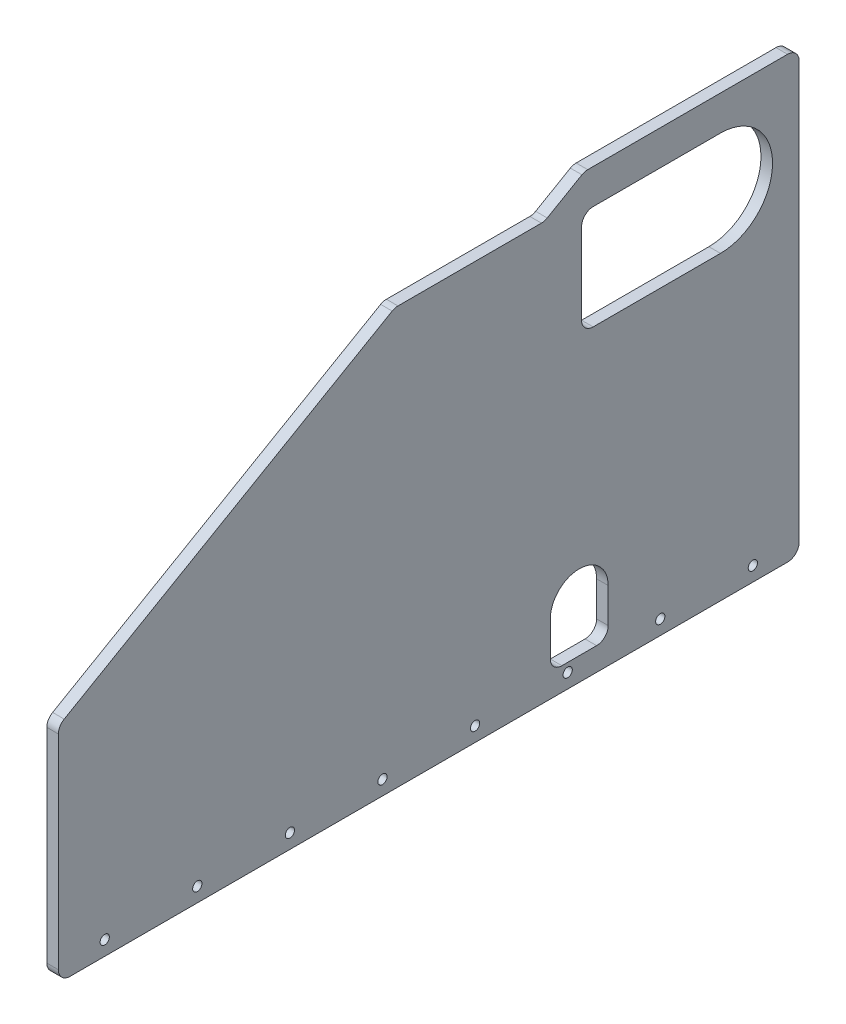
from build123d import *

# Parameters (mm, degrees)
BOSS_EXTRUDE1_DEPTH = 6.35
SKETCH3_R           = 3.96875
CUT_EXTRUDE1_DEPTH  = 7.35
SKETCH5_W           = 6.35
SKETCH5_H           = 12.7
CUT_EXTRUDE3_DEPTH  = 7.35
LPATTERN1_COUNT     = 16
LPATTERN1_PITCH     = 25.4
SKETCH6_W           = 6.35
SKETCH6_H           = 12.7
CUT_EXTRUDE4_DEPTH  = 7.35
LPATTERN2_COUNT     = 11
LPATTERN2_PITCH     = 25.4
SKETCH7_W           = 6.35
SKETCH7_H           = 12.7
SKETCH7_W_2         = 12.7
SKETCH7_H_2         = 6.35
CUT_EXTRUDE5_DEPTH  = 7.35
CUT_EXTRUDE6_DEPTH  = 7.35
LPATTERN3_COUNT     = 10
LPATTERN3_PITCH     = 25.4
SKETCH9_W           = 12.7
SKETCH9_H           = 6.35
CUT_EXTRUDE7_DEPTH  = 7.35
LPATTERN4_COUNT     = 8
LPATTERN4_PITCH     = 25.4
SKETCH10_R          = 3.175
CUT_EXTRUDE8_DEPTH  = 7.35
SKETCH11_R          = 3.96875
CUT_EXTRUDE9_DEPTH  = 7.35
SKETCH12_W          = 6.35
SKETCH12_H          = 12.7
CUT_EXTRUDE13_DEPTH = 7.35
CUT_EXTRUDE15_DEPTH = 7.35
CUT_EXTRUDE16_DEPTH = 7.35
SKETCH17_W          = 12.7
SKETCH17_H          = 6.35
CUT_EXTRUDE17_DEPTH = 7.35
LPATTERN5_COUNT     = 17
LPATTERN5_PITCH     = 25.4
LPATTERN6_COUNT     = 2
LPATTERN6_PITCH     = 120.65
SKETCH18_W          = 12.7
SKETCH18_H          = 6.35
CUT_EXTRUDE18_DEPTH = 7.35
LPATTERN7_COUNT     = 5
LPATTERN7_PITCH     = 25.4
CUT_EXTRUDE19_DEPTH = 7.35
SKETCH20_W          = 101.6
SKETCH20_H          = 57.15
CUT_EXTRUDE20_DEPTH = 7.35
CUT_EXTRUDE21_DEPTH = 7.35
CUT_EXTRUDE22_DEPTH = 7.35
BOSS_EXTRUDE4_DEPTH = 6.35
BOSS_EXTRUDE5_DEPTH = 6.35
CUT_EXTRUDE23_DEPTH = 7.35
CUT_EXTRUDE24_DEPTH = 7.35
FILLET1_R           = 6.35
SKETCH30_R          = 2.54
CUT_EXTRUDE25_DEPTH = 7.35
SKETCH31_W          = 76.2
SKETCH31_H          = 57.15
CUT_EXTRUDE26_DEPTH = 7.35
CUT_EXTRUDE27_DEPTH = 7.35
SKETCH33_W          = 110.352574347
SKETCH33_H          = 42.11476807
CUT_EXTRUDE28_DEPTH = 7.35
FILLET2_R           = 6.35


with BuildPart() as part:
    # Sketch2 → Boss-Extrude1 (new body)
    with BuildSketch(Plane(origin=(0, 0, 0), x_dir=(0, 0, -1), z_dir=(1, 0, 0))):
        Polygon((0, 0), (0, 294.450076882), (215.9, 419.1), (431.8, 419.1), (431.8, 0), (241.3, 0), (241.3, 38.1), (127, 38.1), (127, 0), align=None)
    extrude(amount=BOSS_EXTRUDE1_DEPTH)

    # Sketch3 → Cut-Extrude1 (cut, through all)
    with BuildSketch(Plane(origin=(6.35, 0, 0), x_dir=(0, 0, -1), z_dir=(1, 0, 0))):
        with Locations((63.5, 38.1)):
            Circle(SKETCH3_R)
        with Locations((368.3, 38.1)):
            Circle(SKETCH3_R)
    extrude(amount=-CUT_EXTRUDE1_DEPTH, mode=Mode.SUBTRACT)

    # Sketch5 → Cut-Extrude3 (cut, through all)
    with BuildSketch(Plane(origin=(6.35, 0, 0), x_dir=(0, 0, -1), z_dir=(1, 0, 0))):
        with Locations((428.625, 19.05)):
            Rectangle(SKETCH5_W, SKETCH5_H)
    cut_extrude3 = extrude(amount=-CUT_EXTRUDE3_DEPTH, mode=Mode.SUBTRACT)

    # LPattern1: Cut-Extrude3 ×16
    with Locations(*[(0, i * LPATTERN1_PITCH, 0) for i in range(1, LPATTERN1_COUNT)]):
        add(cut_extrude3, mode=Mode.SUBTRACT)

    # Sketch6 → Cut-Extrude4 (cut, through all)
    with BuildSketch(Plane(origin=(6.35, 0, 0), x_dir=(0, 0, -1), z_dir=(1, 0, 0))):
        with Locations((3.175, 19.05)):
            Rectangle(SKETCH6_W, SKETCH6_H)
    cut_extrude4 = extrude(amount=-CUT_EXTRUDE4_DEPTH, mode=Mode.SUBTRACT)

    # LPattern2: Cut-Extrude4 ×11
    with Locations(*[(0, i * LPATTERN2_PITCH, 0) for i in range(1, LPATTERN2_COUNT)]):
        add(cut_extrude4, mode=Mode.SUBTRACT)

    # Sketch7 → Cut-Extrude5 (cut, through all)
    with BuildSketch(Plane(origin=(6.35, 0, 0), x_dir=(0, 0, -1), z_dir=(1, 0, 0))):
        with Locations((123.825, 19.05)):
            Rectangle(SKETCH7_W, SKETCH7_H)
        with Locations((133.35, 41.275)):
            Rectangle(SKETCH7_W_2, SKETCH7_H_2)
        with Locations((158.75, 41.275)):
            Rectangle(SKETCH7_W_2, SKETCH7_H_2)
        with Locations((184.15, 41.275)):
            Rectangle(SKETCH7_W_2, SKETCH7_H_2)
        with Locations((244.475, 19.05)):
            Rectangle(SKETCH7_W, SKETCH7_H)
        with Locations((209.55, 41.275)):
            Rectangle(SKETCH7_W_2, SKETCH7_H_2)
        with Locations((234.95, 41.275)):
            Rectangle(SKETCH7_W_2, SKETCH7_H_2)
    extrude(amount=-CUT_EXTRUDE5_DEPTH, mode=Mode.SUBTRACT)

    # Sketch8 → Cut-Extrude6 (cut, through all)
    with BuildSketch(Plane(origin=(6.35, 0, 0), x_dir=(0, 0, -1), z_dir=(1, 0, 0))):
        Polygon((201.93507044, 411.037344159), (212.933593068, 417.387344159), (216.108593068, 411.888082845), (205.11007044, 405.538082845), align=None)
    cut_extrude6 = extrude(amount=-CUT_EXTRUDE6_DEPTH, mode=Mode.SUBTRACT)

    # LPattern3: Cut-Extrude6 ×10
    with Locations(*[Vector(0, -0.5, 0.866025404) * (i * LPATTERN3_PITCH) for i in range(1, LPATTERN3_COUNT)]):
        add(cut_extrude6, mode=Mode.SUBTRACT)

    # Sketch9 → Cut-Extrude7 (cut, through all)
    with BuildSketch(Plane(origin=(6.35, 0, 0), x_dir=(0, 0, -1), z_dir=(1, 0, 0))):
        with Locations((412.75, 415.925)):
            Rectangle(SKETCH9_W, SKETCH9_H)
    cut_extrude7 = extrude(amount=-CUT_EXTRUDE7_DEPTH, mode=Mode.SUBTRACT)

    # LPattern4: Cut-Extrude7 ×8
    with Locations(*[(0, 0, i * LPATTERN4_PITCH) for i in range(1, LPATTERN4_COUNT)]):
        add(cut_extrude7, mode=Mode.SUBTRACT)

    # Sketch10 → Cut-Extrude8 (cut, through all)
    with BuildSketch(Plane(origin=(6.35, 0, 0), x_dir=(0, 0, -1), z_dir=(1, 0, 0))):
        with Locations((222.25, 273.05)):
            Circle(SKETCH10_R)
        with Locations((222.25, 57.15)):
            Circle(SKETCH10_R)
        with Locations((146.05, 57.15)):
            Circle(SKETCH10_R)
        with Locations((146.05, 273.05)):
            Circle(SKETCH10_R)
    extrude(amount=-CUT_EXTRUDE8_DEPTH, mode=Mode.SUBTRACT)

    # Sketch11 → Cut-Extrude9 (cut, through all)
    with BuildSketch(Plane(origin=(6.35, 0, 0), x_dir=(0, 0, -1), z_dir=(1, 0, 0))):
        with Locations((38.1, 260.35)):
            Circle(SKETCH11_R)
        with Locations((266.7, 260.35)):
            Circle(SKETCH11_R)
    extrude(amount=-CUT_EXTRUDE9_DEPTH, mode=Mode.SUBTRACT)

    # Sketch12 → Cut-Extrude13 (cut, through all)
    with BuildSketch(Plane(origin=(6.35, 0, 0), x_dir=(0, 0, -1), z_dir=(1, 0, 0))):
        with Locations((123.825, 44.45)):
            Rectangle(SKETCH12_W, SKETCH12_H)
        with Locations((123.825, 69.85)):
            Rectangle(SKETCH12_W, SKETCH12_H)
        with Locations((123.825, 95.25)):
            Rectangle(SKETCH12_W, SKETCH12_H)
        with Locations((123.825, 120.65)):
            Rectangle(SKETCH12_W, SKETCH12_H)
    cut_extrude13 = extrude(amount=-CUT_EXTRUDE13_DEPTH, mode=Mode.SUBTRACT)

    # Sketch14 → Cut-Extrude15 (cut, through all)
    with BuildSketch(Plane(origin=(6.35, 0, 0), x_dir=(0, 0, -1), z_dir=(1, 0, 0))):
        Polygon((36.957231019, 315.787344159), (47.955753647, 322.137344159), (51.130753647, 316.638082845), (40.132231019, 310.288082845), align=None)
        Polygon((80.951321531, 341.187344159), (91.949844159, 347.537344159), (95.124844159, 342.038082845), (84.126321531, 335.688082845), align=None)
    extrude(amount=-CUT_EXTRUDE15_DEPTH, mode=Mode.SUBTRACT)

    # Sketch15 → Cut-Extrude16 (cut, through all)
    with BuildSketch(Plane(origin=(6.35, 0, 0), x_dir=(0, 0, -1), z_dir=(1, 0, 0))):
        with BuildLine():
            Line((62.129276275, 322.988082845), (31.558579521, 305.338082845))
            ThreePointArc((31.558579521, 305.338082845), (51.535904978, 302.314952438), (62.501260575, 319.285333297))
            ThreePointArc((62.501260575, 319.285333297), (62.408031035, 321.146027155), (62.129276275, 322.988082845))
        make_face()
        with BuildLine():
            Line((103.698495657, 346.988082845), (73.127798903, 329.338082845))
            ThreePointArc((73.127798903, 329.338082845), (93.10512436, 326.314952438), (104.070479957, 343.285333297))
            ThreePointArc((104.070479957, 343.285333297), (103.977250417, 345.146027155), (103.698495657, 346.988082845))
        make_face()
    extrude(amount=-CUT_EXTRUDE16_DEPTH, mode=Mode.SUBTRACT)

    # Sketch17 → Cut-Extrude17 (cut, through all)
    with BuildSketch(Plane(origin=(6.35, 0, 0), x_dir=(0, 0, -1), z_dir=(1, 0, 0))):
        with Locations((25.4, 142.875)):
            Rectangle(SKETCH17_W, SKETCH17_H)
    cut_extrude17 = extrude(amount=-CUT_EXTRUDE17_DEPTH, mode=Mode.SUBTRACT)

    # LPattern5: Cut-Extrude17 ×17
    with Locations(*[(0, 0, -i * LPATTERN5_PITCH) for i in range(1, LPATTERN5_COUNT)]):
        add(cut_extrude17, mode=Mode.SUBTRACT)

    # LPattern6: Cut-Extrude13 ×2
    with Locations(*[(0, 0, -i * LPATTERN6_PITCH) for i in range(1, LPATTERN6_COUNT)]):
        add(cut_extrude13, mode=Mode.SUBTRACT)

    # Sketch18 → Cut-Extrude18 (cut, through all)
    with BuildSketch(Plane(origin=(6.35, 0, 0), x_dir=(0, 0, -1), z_dir=(1, 0, 0))):
        with Locations((133.35, 117.475)):
            Rectangle(SKETCH18_W, SKETCH18_H)
    cut_extrude18 = extrude(amount=-CUT_EXTRUDE18_DEPTH, mode=Mode.SUBTRACT)

    # LPattern7: Cut-Extrude18 ×5
    with Locations(*[(0, 0, -i * LPATTERN7_PITCH) for i in range(1, LPATTERN7_COUNT)]):
        add(cut_extrude18, mode=Mode.SUBTRACT)

    # Sketch19 → Cut-Extrude19 (cut, through all)
    with BuildSketch(Plane(origin=(6.35, 0, 0), x_dir=(0, 0, -1), z_dir=(1, 0, 0))):
        Polygon((25.4, 279.785380045), (222.705909488, 393.7), (406.4, 393.7), (406.4, 165.1), (25.4, 165.1), align=None)
    extrude(amount=-CUT_EXTRUDE19_DEPTH, mode=Mode.SUBTRACT)

    # Sketch20 → Cut-Extrude20 (cut, through all)
    with BuildSketch(Plane(origin=(6.35, 0, 0), x_dir=(0, 0, -1), z_dir=(1, 0, 0))):
        with Locations((184.15, 79.375)):
            Rectangle(SKETCH20_W, SKETCH20_H)
    extrude(amount=-CUT_EXTRUDE20_DEPTH, mode=Mode.SUBTRACT)

    # Sketch21 → Cut-Extrude21 (cut, through all)
    with BuildSketch(Plane(origin=(6.35, 0, 0), x_dir=(0, 0, -1), z_dir=(1, 0, 0))):
        Polygon((266.7, 25.4), (308.202954744, 25.4), (406.4, 82.094090512), (406.4, 133.35), (266.7, 133.35), align=None)
        Polygon((25.4, 133.35), (25.4, 82.094090512), (101.6, 38.1), (101.6, 133.35), align=None)
        Polygon((25.4, 38.1), (25.4, 25.4), (47.397045256, 25.4), align=None)
    extrude(amount=-CUT_EXTRUDE21_DEPTH, mode=Mode.SUBTRACT)

    # Sketch22 → Cut-Extrude22 (cut, through all)
    with BuildSketch(Plane(origin=(6.35, 0, 0), x_dir=(0, 0, -1), z_dir=(1, 0, 0))):
        Polygon((384.402954744, 25.4), (406.4, 38.1), (406.4, 25.4), align=None)
    extrude(amount=-CUT_EXTRUDE22_DEPTH, mode=Mode.SUBTRACT)

    # Sketch26 → Boss-Extrude4 (add, through all)
    with BuildSketch(Plane(origin=(6.35, 0, 0), x_dir=(0, 0, -1), z_dir=(1, 0, 0))):
        Polygon((266.7, 133.35), (266.7, 126.280871047), (278.944090512, 133.35), align=None)
        Polygon((89.355909488, 133.35), (101.6, 126.280871047), (101.6, 133.35), align=None)
        Polygon((266.7, 32.469128953), (278.944090512, 25.4), (266.7, 25.4), align=None)
        Polygon((133.35, 107.95), (133.35, 100.880871047), (145.594090512, 107.95), align=None)
        Polygon((234.95, 107.95), (222.705909488, 107.95), (234.95, 100.880871047), align=None)
        Polygon((133.35, 50.8), (145.594090512, 50.8), (133.35, 57.869128953), align=None)
        Polygon((234.95, 50.8), (222.705909488, 50.8), (234.95, 57.869128953), align=None)
    extrude(amount=-BOSS_EXTRUDE4_DEPTH)


with BuildPart() as body_2:
    # Sketch27 → Boss-Extrude5 (new body)
    with BuildSketch(Plane(origin=(6.35, 0, 0), x_dir=(0, 0, -1), z_dir=(1, 0, 0))):
        Polygon((12.7, 165.1), (12.7, 287.117728463), (219.302954744, 406.4), (419.1, 406.4), (419.1, 165.1), align=None)
    extrude(amount=-BOSS_EXTRUDE5_DEPTH)

    # Sketch28 → Cut-Extrude23 (cut, through all)
    with BuildSketch(Plane(origin=(6.35, 0, 0), x_dir=(0, 0, -1), z_dir=(1, 0, 0))):
        Polygon((251.052954744, 406.4), (273.05, 393.7), (279.4, 393.7), (301.397045256, 406.4), align=None)
    extrude(amount=-CUT_EXTRUDE23_DEPTH, mode=Mode.SUBTRACT)

    # Sketch29 → Cut-Extrude24 (cut, through all)
    with BuildSketch(Plane(origin=(6.35, 0, 0), x_dir=(0, 0, -1), z_dir=(1, 0, 0))):
        with BuildLine():
            Line((282.575, 203.2), (282.575, 177.8))
            Line((282.575, 177.8), (314.325, 177.8))
            Line((314.325, 177.8), (314.325, 203.2))
            ThreePointArc((314.325, 203.2), (298.45, 219.075), (282.575, 203.2))
        make_face()
    extrude(amount=-CUT_EXTRUDE24_DEPTH, mode=Mode.SUBTRACT)

    # Fillet1
    fillet1_edges = [body_2.edges().sort_by_distance(p)[0] for p in [
        (3.175, 406.4, -251.052954744),
        (3.175, 406.4, -301.397045256),
        (3.175, 393.7, -279.4),
        (3.175, 393.7, -273.05),
        (3.175, 177.8, -314.325),
        (3.175, 177.8, -282.575),
        (3.175, 165.1, -12.7),
        (3.175, 287.117728463, -12.7),
        (3.175, 406.4, -219.302954744),
        (3.175, 406.4, -419.1),
        (3.175, 165.1, -419.1),
    ]]
    fillet(fillet1_edges, radius=FILLET1_R)

    # Sketch30 → Cut-Extrude25 (cut, through all)
    with BuildSketch(Plane(origin=(6.35, 0, 0), x_dir=(0, 0, -1), z_dir=(1, 0, 0))):
        with Locations((38.1, 173.0375)):
            Circle(SKETCH30_R)
        with Locations((88.9, 173.0375)):
            Circle(SKETCH30_R)
        with Locations((139.7, 173.0375)):
            Circle(SKETCH30_R)
        with Locations((190.5, 173.0375)):
            Circle(SKETCH30_R)
        with Locations((241.3, 173.0375)):
            Circle(SKETCH30_R)
        with Locations((292.1, 173.0375)):
            Circle(SKETCH30_R)
        with Locations((342.9, 173.0375)):
            Circle(SKETCH30_R)
        with Locations((393.7, 173.0375)):
            Circle(SKETCH30_R)
    extrude(amount=-CUT_EXTRUDE25_DEPTH, mode=Mode.SUBTRACT)

    # Sketch31 → Cut-Extrude26 (cut, through all)
    with BuildSketch(Plane(origin=(6.35, 0, 0), x_dir=(0, 0, -1), z_dir=(1, 0, 0))):
        with Locations((337.82499999, 358.775)):
            Rectangle(SKETCH31_W, SKETCH31_H)
    extrude(amount=-CUT_EXTRUDE26_DEPTH, mode=Mode.SUBTRACT)

    # Sketch32 → Cut-Extrude27 (cut, through all)
    with BuildSketch(Plane(origin=(6.35, 0, 0), x_dir=(0, 0, -1), z_dir=(1, 0, 0))):
        with BuildLine():
            Line((375.92499999, 387.35), (375.92499999, 330.2))
            ThreePointArc((375.92499999, 330.2), (404.49999999, 358.775), (375.92499999, 387.35))
        make_face()
    extrude(amount=-CUT_EXTRUDE27_DEPTH, mode=Mode.SUBTRACT)

    # Sketch33 → Cut-Extrude28 (cut, through all)
    with BuildSketch(Plane(origin=(6.35, 0, 0), x_dir=(0, 0, -1), z_dir=(1, 0, 0))):
        with Locations((219.575190199, 414.757384035)):
            Rectangle(SKETCH33_W, SKETCH33_H)
    extrude(amount=-CUT_EXTRUDE28_DEPTH, mode=Mode.SUBTRACT)

    # Fillet2
    fillet2_edges = [body_2.edges().sort_by_distance(p)[0] for p in [
        (3.175, 330.2, -299.72499999),
        (3.175, 387.35, -299.72499999),
        (3.175, 393.7, -197.305909488),
    ]]
    fillet(fillet2_edges, radius=FILLET2_R)


solid = body_2.part
